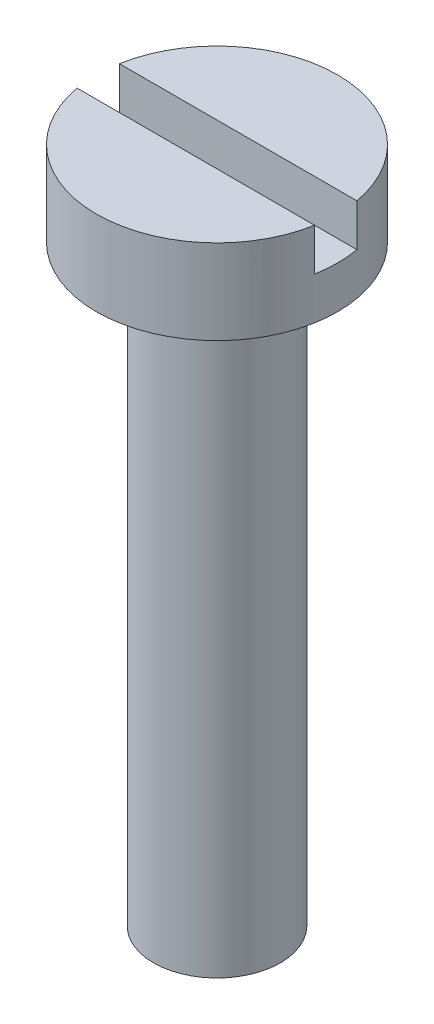
from build123d import *

# Parameters (mm, degrees)
SKETCH1_R           = 2.85
BOSS_EXTRUDE1_DEPTH = 2
SKETCH2_R           = 1.5
BOSS_EXTRUDE2_DEPTH = 14
SKETCH3_W           = 6
SKETCH3_H           = 1
CUT_EXTRUDE1_DEPTH  = 1


with BuildPart() as part:
    # Sketch1 → Boss-Extrude1 (new body)
    with BuildSketch(Plane(origin=(0, 0, 0), x_dir=(1, 0, 0), z_dir=(0, 1, 0))):
        Circle(SKETCH1_R)
    extrude(amount=BOSS_EXTRUDE1_DEPTH)

    # Sketch2 → Boss-Extrude2 (add)
    with BuildSketch(Plane(origin=(0, 0, 0), x_dir=(1, 0, 0), z_dir=(0, 1, 0))):
        Circle(SKETCH2_R)
    extrude(amount=-BOSS_EXTRUDE2_DEPTH)

    # Sketch3 → Cut-Extrude1 (cut)
    with BuildSketch(Plane(origin=(0, 2, 0), x_dir=(1, 0, 0), z_dir=(0, 1, 0))):
        Rectangle(SKETCH3_W, SKETCH3_H)
    extrude(amount=-CUT_EXTRUDE1_DEPTH, mode=Mode.SUBTRACT)


solid = part.part
